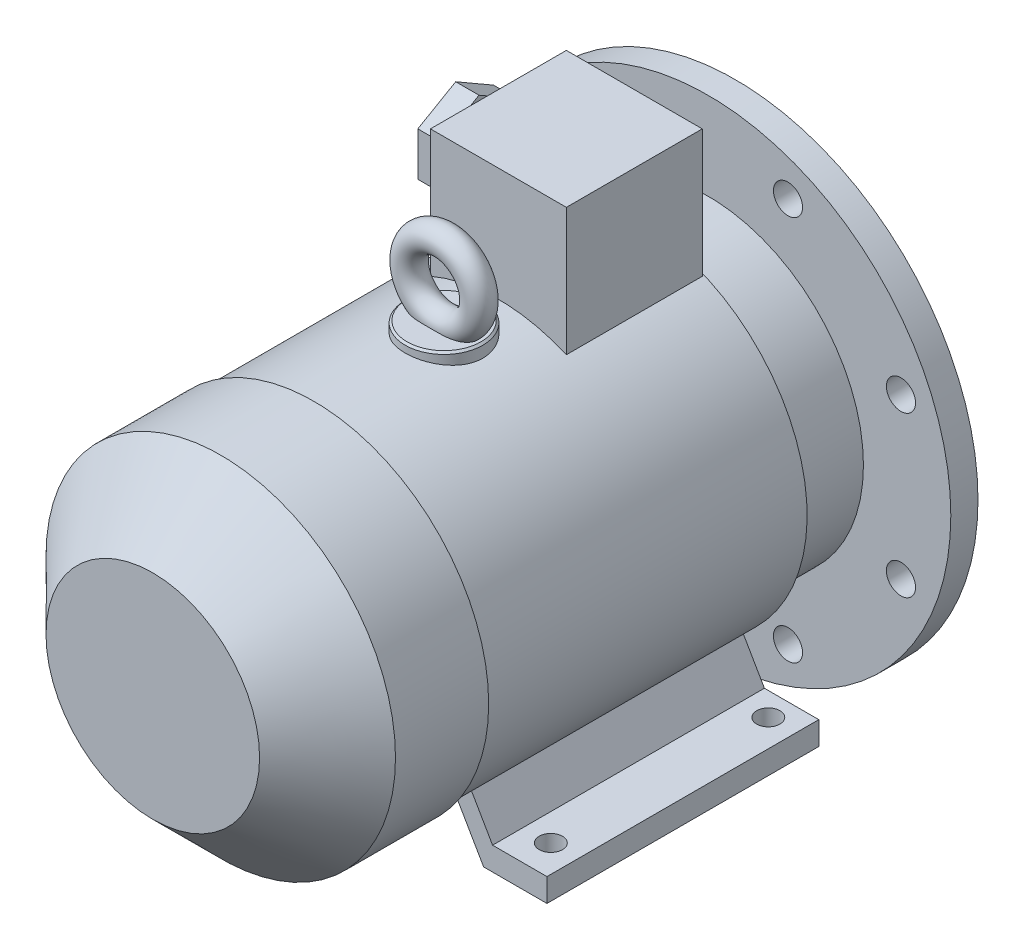
from build123d import *

# Parameters (mm, degrees)
SKETCH_1_R           = 14
EXTRUDE_1_DEPTH      = 60
SKETCH_2_W           = 7
SKETCH_2_H           = 7
EXTRUDE_2_DEPTH      = 0.1
EXTRUDE_2_DEPTH_BACK = 30
SKETCH_3_R           = 125
EXTRUDE_3_DEPTH      = 14
SKETCH_4_R           = 90
SKETCH_4_R_2         = 85
EXTRUDE_4_DEPTH      = 4
SKETCH_5_R           = 85
SKETCH_5_R_2         = 25
CUT_EXTRUDE_1_DEPTH  = 8
CHAMFER_1_SIZE       = 1
SKETCH_6_R           = 7.5
CUT_EXTRUDE_2_DEPTH  = 15
SKETCH_7_R           = 80
EXTRUDE_5_DEPTH      = 37
SKETCH_8_R           = 88
EXTRUDE_6_DEPTH      = 166
SKETCH_9_R           = 90
EXTRUDE_7_DEPTH      = 83
CHAMFER_2_SIZE       = 35
EXTRUDE_8_DEPTH      = 140
CUT_EXTRUDE_3_REACH  = 227
SKETCH_11_R          = 6
SKETCH_12_W          = 70
SKETCH_12_H          = 70
EXTRUDE_9_DEPTH      = 146.5
SKETCH_13_R          = 20
EXTRUDE_10_DEPTH     = 92.5
CHAMFER_3_SIZE       = 1
SKETCH_15_R          = 7
SKETCH_16_R          = 15
EXTRUDE_11_DEPTH     = 10
EXTRUDE_12_DEPTH     = 12
SKETCH_18_R          = 8
CUT_EXTRUDE_4_DEPTH  = 12


with BuildPart() as part:
    # Эскиз1 → Вытянуть1 (new body)
    with BuildSketch(Plane.XY):
        Circle(SKETCH_1_R)
    extrude(amount=EXTRUDE_1_DEPTH)

    # Эскиз2 → Вытянуть2 (add, two sides)
    with BuildSketch(Plane(origin=(0, 0, 0), x_dir=(-1, 0, 0), z_dir=(0, 0, -1))) as extrude_2_sk:
        with Locations((0, 13.5)):
            Rectangle(SKETCH_2_W, SKETCH_2_H)
    extrude(amount=EXTRUDE_2_DEPTH)
    extrude(extrude_2_sk.sketch, amount=-EXTRUDE_2_DEPTH_BACK)

    # Эскиз3 → Вытянуть3 (add)
    with BuildSketch(Plane.XY.offset(60)):
        Circle(SKETCH_3_R)
    extrude(amount=EXTRUDE_3_DEPTH)

    # Эскиз4 → Вытянуть4 (add)
    with BuildSketch(Plane(origin=(0, 0, 60), x_dir=(-1, 0, 0), z_dir=(0, 0, -1))):
        with Locations(Location((0, 0, 0), (0, 0, 180))):  # turned: the seam where the file's is
            Circle(SKETCH_4_R)
        Circle(SKETCH_4_R_2, mode=Mode.SUBTRACT)
    extrude(amount=EXTRUDE_4_DEPTH)

    # Эскиз5 → Вырез-Вытянуть1 (cut)
    with BuildSketch(Plane(origin=(0, 0, 60), x_dir=(-1, 0, 0), z_dir=(0, 0, -1))):
        Circle(SKETCH_5_R)
        Circle(SKETCH_5_R_2, mode=Mode.SUBTRACT)
    extrude(amount=-CUT_EXTRUDE_1_DEPTH, mode=Mode.SUBTRACT)

    # Фаска1
    chamfer_1_edges = [part.edges().sort_by_distance(p)[0] for p in [
        (-90, 0, 56),
        (25, 0, 60),
        (-8.5732141, -11.067971811, 0),
    ]]
    chamfer(chamfer_1_edges, length=CHAMFER_1_SIZE)

    # Эскиз6 → Вырез-Вытянуть2 (cut, through all)
    with BuildSketch(Plane(origin=(0, 0, 60), x_dir=(-1, 0, 0), z_dir=(0, 0, -1))):
        with Locations((-41.138468979, 99.317049745)):
            Circle(SKETCH_6_R)
        with Locations((41.138468979, 99.317049745)):
            Circle(SKETCH_6_R)
        with Locations((99.317049745, 41.138468979)):
            Circle(SKETCH_6_R)
        with Locations((99.317049745, -41.138468979)):
            Circle(SKETCH_6_R)
        with Locations((41.138468979, -99.317049745)):
            Circle(SKETCH_6_R)
        with Locations((-41.138468979, -99.317049745)):
            Circle(SKETCH_6_R)
        with Locations((-99.317049745, -41.138468979)):
            Circle(SKETCH_6_R)
        with Locations((-99.317049745, 41.138468979)):
            Circle(SKETCH_6_R)
    extrude(amount=-CUT_EXTRUDE_2_DEPTH, mode=Mode.SUBTRACT)

    # Эскиз7 → Вытянуть5 (add)
    with BuildSketch(Plane.XY.offset(74)):
        Circle(SKETCH_7_R)
    extrude(amount=EXTRUDE_5_DEPTH)

    # Эскиз8 → Вытянуть6 (add)
    with BuildSketch(Plane.XY.offset(111)):
        Circle(SKETCH_8_R)
    extrude(amount=EXTRUDE_6_DEPTH)

    # Эскиз9 → Вытянуть7 (add)
    with BuildSketch(Plane.XY.offset(277)):
        Circle(SKETCH_9_R)
    extrude(amount=EXTRUDE_7_DEPTH)

    # Фаска2
    chamfer_2_edges = [part.edges().sort_by_distance(p)[0] for p in [
        (-90, 0, 360),
    ]]
    chamfer(chamfer_2_edges, length=CHAMFER_2_SIZE)

    # Эскиз10 → Вытянуть8 (add)
    with BuildSketch(Plane(origin=(0, 0, 111), x_dir=(-1, 0, 0), z_dir=(0, 0, -1))):
        Polygon((-94, -100), (-61.381197846, -100), (-42.28463326, -66.923779886), (-50.944887298, -61.923779886), (-66, -88), (-94, -88), align=None)
        Polygon((61.381197846, -100), (42.28463326, -66.923779886), (50.944887298, -61.923779886), (66, -88), (94, -88), (94, -100), align=None)
    extrude(amount=-EXTRUDE_8_DEPTH)

    # Эскиз11 → Вырез-Вытянуть3 (cut, up to next)
    with BuildSketch(Plane.XZ.offset(100), mode=Mode.PRIVATE) as cut_extrude_3_sk1:
        with Locations(Location((-80, 123, 0), (0, 0, 270))):  # turned: the seam where the file's is
            Circle(SKETCH_11_R)
    cut_extrude_3_tool1 = extrude(cut_extrude_3_sk1.sketch, amount=-CUT_EXTRUDE_3_REACH, mode=Mode.PRIVATE) & part.part
    add(cut_extrude_3_tool1.solids().sort_by_distance((-80, -100, 123))[0], mode=Mode.SUBTRACT)
    # Эскиз11 → Вырез-Вытянуть3 (cut, up to next)
    with BuildSketch(Plane.XZ.offset(100), mode=Mode.PRIVATE) as cut_extrude_3_sk2:
        with Locations(Location((80, 123, 0), (0, 0, 270))):  # turned: the seam where the file's is
            Circle(SKETCH_11_R)
    cut_extrude_3_tool2 = extrude(cut_extrude_3_sk2.sketch, amount=-CUT_EXTRUDE_3_REACH, mode=Mode.PRIVATE) & part.part
    add(cut_extrude_3_tool2.solids().sort_by_distance((80, -100, 123))[0], mode=Mode.SUBTRACT)
    # Эскиз11 → Вырез-Вытянуть3 (cut, up to next)
    with BuildSketch(Plane.XZ.offset(100), mode=Mode.PRIVATE) as cut_extrude_3_sk3:
        with Locations(Location((-80, 235, 0), (0, 0, 270))):  # turned: the seam where the file's is
            Circle(SKETCH_11_R)
    cut_extrude_3_tool3 = extrude(cut_extrude_3_sk3.sketch, amount=-CUT_EXTRUDE_3_REACH, mode=Mode.PRIVATE) & part.part
    add(cut_extrude_3_tool3.solids().sort_by_distance((-80, -100, 235))[0], mode=Mode.SUBTRACT)
    # Эскиз11 → Вырез-Вытянуть3 (cut, up to next)
    with BuildSketch(Plane.XZ.offset(100), mode=Mode.PRIVATE) as cut_extrude_3_sk4:
        with Locations(Location((80, 235, 0), (0, 0, 270))):  # turned: the seam where the file's is
            Circle(SKETCH_11_R)
    cut_extrude_3_tool4 = extrude(cut_extrude_3_sk4.sketch, amount=-CUT_EXTRUDE_3_REACH, mode=Mode.PRIVATE) & part.part
    add(cut_extrude_3_tool4.solids().sort_by_distance((80, -100, 235))[0], mode=Mode.SUBTRACT)

    # Эскиз12 → Вытянуть9 (add)
    with BuildSketch(Plane(origin=(0, 0, 0), x_dir=(1, 0, 0), z_dir=(0, 1, 0))):
        with Locations((0, -147)):
            Rectangle(SKETCH_12_W, SKETCH_12_H)
    extrude(amount=EXTRUDE_9_DEPTH)

    # Эскиз13 → Вытянуть10 (add)
    with BuildSketch(Plane(origin=(0, 0, 0), x_dir=(1, 0, 0), z_dir=(0, 1, 0))):
        with Locations(Location((0, -210, 0), (0, 0, 90))):  # turned: the seam where the file's is
            Circle(SKETCH_13_R)
    extrude(amount=EXTRUDE_10_DEPTH)

    # Фаска3
    chamfer_3_edges = [part.edges().sort_by_distance(p)[0] for p in [
        (0, 92.5, 230),
    ]]
    chamfer(chamfer_3_edges, length=CHAMFER_3_SIZE)

    # По траектории1: sweep along a path in Эскиз14
    with BuildLine(Plane.XY.offset(210)) as sweep_1_path:
        CenterArc((0, 110.5), 18, 0, 360)
    # Эскиз15 → По траектории1 (sweep)
    with BuildSketch(Plane(origin=(0, 0, 0), x_dir=(0, 0, -1), z_dir=(1, 0, 0))):
        with Locations((-210, 128.5)):
            Circle(SKETCH_15_R)
    sweep(path=sweep_1_path.line)

    # Эскиз16 → Вытянуть11 (add)
    with BuildSketch(Plane.ZY.offset(35)):
        with Locations(Location((147, 116.5, 0), (0, 0, 180))):  # turned: the seam where the file's is
            Circle(SKETCH_16_R)
    extrude(amount=EXTRUDE_11_DEPTH)

    # Эскиз17 → Вытянуть12 (add)
    with BuildSketch(Plane.ZY.offset(45)):
        Polygon((147, 139.016660498), (127.5, 127.758330249), (127.5, 105.241669751), (147, 93.983339502), (166.5, 105.241669751), (166.5, 127.758330249), align=None)
    extrude(amount=EXTRUDE_12_DEPTH)

    # Эскиз18 → Вырез-Вытянуть4 (cut)
    with BuildSketch(Plane.ZY.offset(57)):
        with Locations((147, 116.5)):
            Circle(SKETCH_18_R)
    extrude(amount=-CUT_EXTRUDE_4_DEPTH, mode=Mode.SUBTRACT)


solid = part.part
